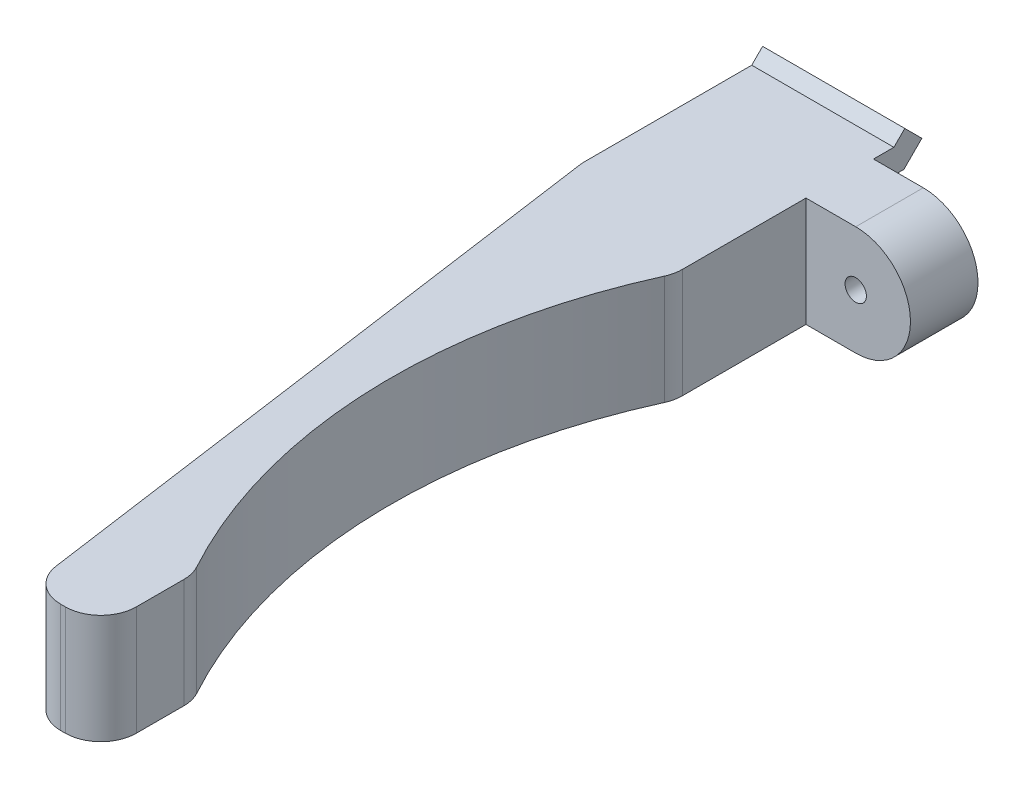
from build123d import *

# Parameters (mm, degrees)
SKETCH2_W           = 10
SKETCH2_H           = 14.768412439
BOSS_EXTRUDE1_DEPTH = 5
BOSS_EXTRUDE4_DEPTH = 10
SKETCH9_W           = 10
SKETCH9_H           = 3.18
SKETCH9_H_2         = 3.888412439
CUT_EXTRUDE3_DEPTH  = 5
BOSS_EXTRUDE5_DEPTH = 7.7
SKETCH12_R          = 0.75
BOSS_EXTRUDE7_DEPTH = 4.75
FILLET1_R           = 2.5


with BuildPart() as part:
    # Sketch2 → Boss-Extrude1 (new body)
    with BuildSketch(Plane.XY):
        with Locations((0, 1.566049366)):
            Rectangle(SKETCH2_W, SKETCH2_H)
    extrude(amount=BOSS_EXTRUDE1_DEPTH)

    # Sketch8 → Boss-Extrude4 (add)
    with BuildSketch(Plane.ZY.offset(5)):
        Polygon((-0.15, 5.770255585), (0, 5.770255585), (0, 4.070255585), (-0.15, 4.070255585), (-2.137867966, 4.070255585), (-3.402081528, 5.334469147), (-2.2, 6.536550675), (-1.43370491, 5.770255585), align=None)
        Polygon((-0.15, -1.929744415), (0, -1.929744415), (0, -0.229744415), (-0.15, -0.229744415), (-1.43370491, -0.229744415), (-2.2, 0.536550675), (-3.402081528, -0.665530853), (-2.137867966, -1.929744415), align=None)
    extrude(amount=-BOSS_EXTRUDE4_DEPTH)

    # Sketch9 → Cut-Extrude3 (cut)
    with BuildSketch(Plane(origin=(0, 0, 0), x_dir=(-1, 0, 0), z_dir=(0, 0, -1))):
        with Locations((0, 7.360255585)):
            Rectangle(SKETCH9_W, SKETCH9_H)
        with Locations((0, -3.873950635)):
            Rectangle(SKETCH9_W, SKETCH9_H_2)
    extrude(amount=-CUT_EXTRUDE3_DEPTH, mode=Mode.SUBTRACT)

    # Sketch10 → Boss-Extrude5 (add)
    with BuildSketch(Plane(origin=(0, 5.770255585, 0), x_dir=(1, 0, 0), z_dir=(0, 1, 0))):
        with BuildLine():
            Line((-5, -5), (-5, -10.5))
            Line((-5, -10.5), (1.352445729, -55.7))
            Line((1.352445729, -55.7), (6.352445729, -55.7))
            Line((6.352445729, -55.7), (6.352445729, -49.2))
            ThreePointArc((6.352445729, -49.2), (1.383429579, -31.764936646), (5, -14))
            Line((5, -14), (5, -5))
            Line((5, -5), (-5, -5))
        make_face()
    extrude(amount=-BOSS_EXTRUDE5_DEPTH)

    # Sketch12 → Boss-Extrude7 (add)
    with BuildSketch(Plane.XY):
        with BuildLine():
            Line((5, 5.770255585), (8.5, 5.770255585))
            ThreePointArc((8.5, 5.770255585), (12.35, 1.920255585), (8.5, -1.929744415))
            Line((8.5, -1.929744415), (5, -1.929744415))
            Line((5, -1.929744415), (5, 5.770255585))
        make_face()
        with Locations((8.5, 1.920255585)):
            Circle(SKETCH12_R, mode=Mode.SUBTRACT)
    extrude(amount=BOSS_EXTRUDE7_DEPTH)

    # Fillet1
    fillet1_edges = [part.edges().sort_by_distance(p)[0] for p in [
        (6.352445729, 1.920255585, 49.2),
        (5, 1.920255585, 14),
        (1.352445729, 1.920255585, 55.7),
        (6.352445729, 1.920255585, 55.7),
    ]]
    fillet(fillet1_edges, radius=FILLET1_R)


solid = part.part
